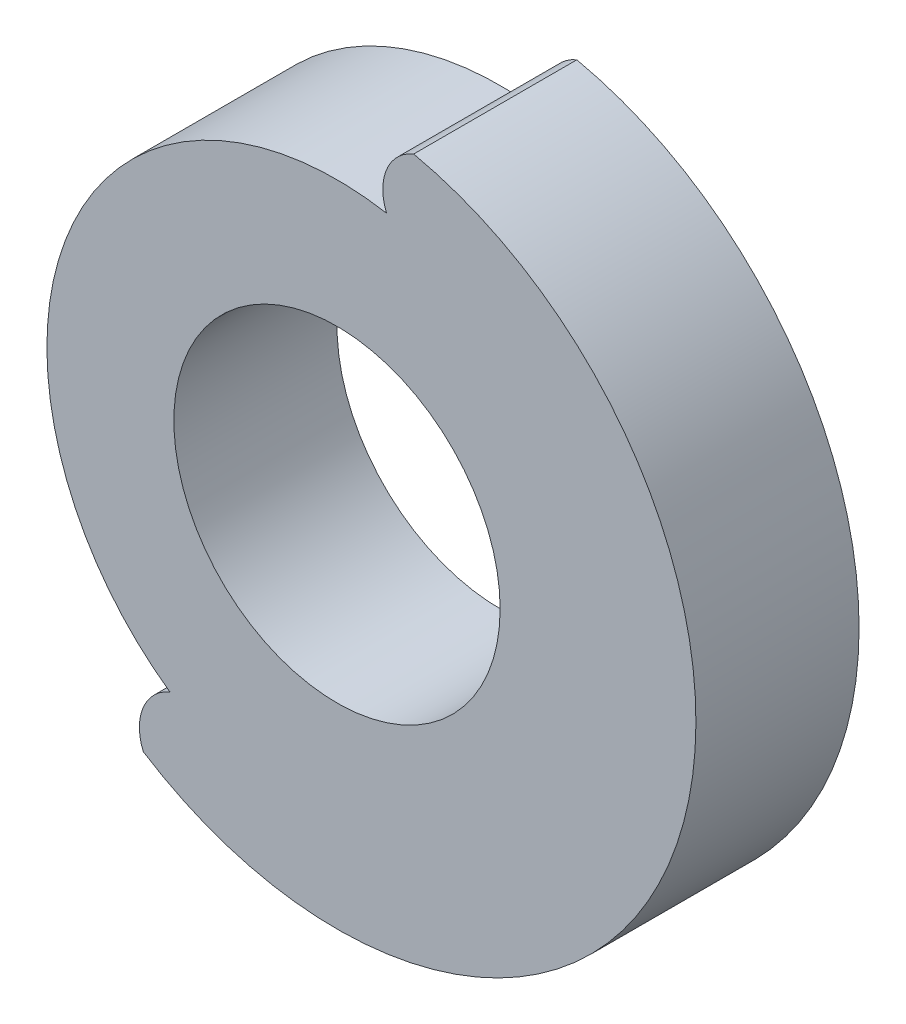
from build123d import *

# Parameters (mm, degrees)
SKETCH1_R           = 13.2
SKETCH1_R_2         = 6
BOSS_EXTRUDE1_DEPTH = 6
CUT_EXTRUDE1_DEPTH  = 7
SKETCH3_R           = 13.2
SKETCH3_R_2         = 6
BOSS_EXTRUDE2_DEPTH = 6
CUT_EXTRUDE2_DEPTH  = 7
CIRPATTERN2_COUNT   = 10
CIRPATTERN2_ANGLE   = 135


with BuildPart() as part:
    # Sketch1 → Boss-Extrude1 (new body)
    with BuildSketch(Plane.XY):
        Circle(SKETCH1_R)
        Circle(SKETCH1_R_2, mode=Mode.SUBTRACT)
    extrude(amount=BOSS_EXTRUDE1_DEPTH)

    # Sketch2 → Cut-Extrude1 (cut, through all)
    with BuildSketch(Plane.XY.offset(6)):
        with BuildLine():
            ThreePointArc((-2.819851171, 12.895287487), (0, 13.2), (2.819851171, 12.895287487))
            ThreePointArc((2.819851171, 12.895287487), (1.826256171, 11.910750525), (1.819851171, 10.512))
            ThreePointArc((1.819851171, 10.512), (0, 10.668364555), (-1.819851171, 10.512))
            ThreePointArc((-1.819851171, 10.512), (-1.826256171, 11.910750525), (-2.819851171, 12.895287487))
        make_face()
    extrude(amount=-CUT_EXTRUDE1_DEPTH, mode=Mode.SUBTRACT)

    # Sketch3 → Boss-Extrude2 (add)
    with BuildSketch(Plane.XY):
        Circle(SKETCH3_R)
        Circle(SKETCH3_R_2, mode=Mode.SUBTRACT)
    extrude(amount=BOSS_EXTRUDE2_DEPTH)

    # Sketch4 → Cut-Extrude2 (cut, through all)
    with BuildSketch(Plane.XY.offset(6)):
        with BuildLine():
            ThreePointArc((-2.819851171, 12.895287487), (0, 13.2), (2.819851171, 12.895287487))
            ThreePointArc((2.819851171, 12.895287487), (1.826256171, 11.910750525), (1.819851171, 10.512))
            ThreePointArc((1.819851171, 10.512), (0, 10.668364555), (-1.819851171, 10.512))
            ThreePointArc((-1.819851171, 10.512), (-1.826256171, 11.910750525), (-2.819851171, 12.895287487))
        make_face()
    cut_extrude2 = extrude(amount=-CUT_EXTRUDE2_DEPTH, mode=Mode.SUBTRACT)

    # CirPattern2: Cut-Extrude2 ×10 about axis
    cirpattern2_axis = Axis((0, 0, 0), (0, 0, 1))
    for i in range(1, CIRPATTERN2_COUNT):
        add(cut_extrude2.rotate(cirpattern2_axis, i * CIRPATTERN2_ANGLE / (CIRPATTERN2_COUNT - 1)), mode=Mode.SUBTRACT)


solid = part.part
